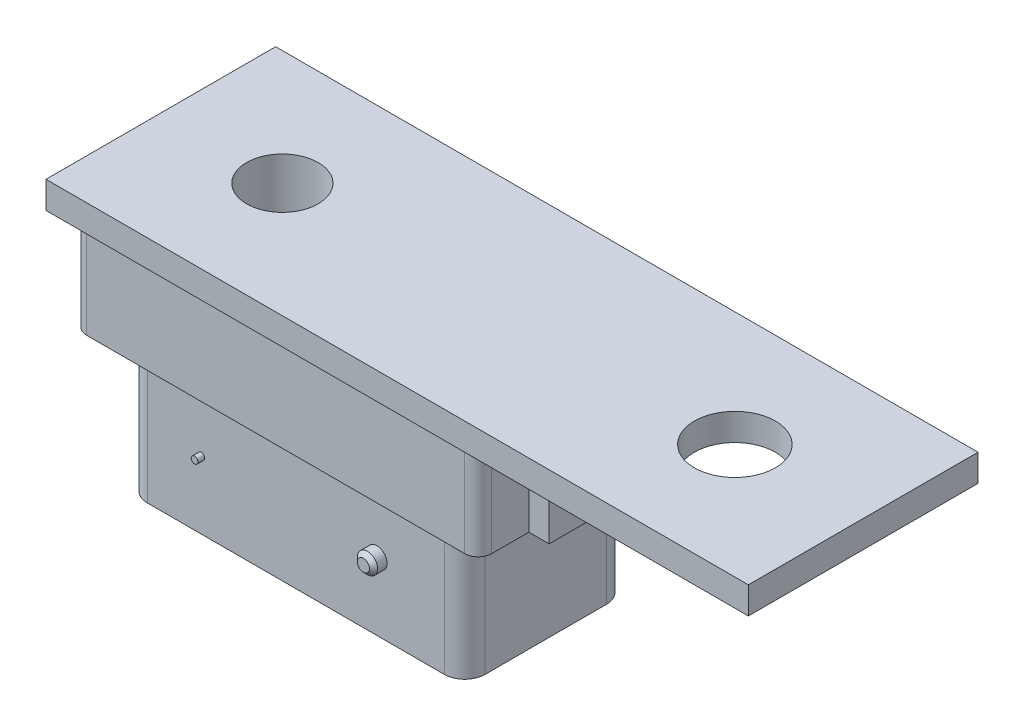
from build123d import *

# Parameters (mm, degrees)
SKETCH1_W           = 520
SKETCH1_H           = 170
BOSS_EXTRUDE1_DEPTH = 10
BOSS_EXTRUDE2_DEPTH = 75
BOSS_EXTRUDE3_DEPTH = 100
SKETCH4_W           = 7.501461654
SKETCH4_H           = 40
BOSS_EXTRUDE4_DEPTH = 25
SKETCH5_R           = 3.75
CUT_EXTRUDE1_DEPTH  = 93
SKETCH6_W           = 50
SKETCH6_H           = 75
BOSS_EXTRUDE5_DEPTH = 5
SKETCH7_R           = 30
CUT_EXTRUDE2_DEPTH  = 68
SKETCH8_W           = 75
SKETCH8_H           = 75
BOSS_EXTRUDE6_DEPTH = 15
SKETCH9_R           = 30
SKETCH9_R_2         = 26.5
BOSS_EXTRUDE7_DEPTH = 5
SKETCH11_R          = 26.5
CUT_EXTRUDE3_DEPTH  = 75
SKETCH12_R          = 26.5
CUT_EXTRUDE4_DEPTH  = 196
SKETCH14_R          = 7.5
BOSS_EXTRUDE8_DEPTH = 10
CHAMFER1_SIZE       = 3
SKETCH15_R          = 2.5
BOSS_EXTRUDE9_DEPTH = 5


with BuildPart() as part:
    # Sketch1 → Boss-Extrude1 (new body, symmetric)
    with BuildSketch(Plane(origin=(0, 0, 0), x_dir=(1, 0, 0), z_dir=(0, 1, 0))):
        Rectangle(SKETCH1_W, SKETCH1_H)
    extrude(amount=BOSS_EXTRUDE1_DEPTH, both=True)

    # Sketch2 → Boss-Extrude2 (add)
    with BuildSketch(Plane.XZ.offset(10)):
        with BuildLine():
            Line((-240, 75), (40, 75))
            ThreePointArc((40, 75), (47.071067812, 72.071067812), (50, 65))
            Line((50, 65), (50, -65))
            ThreePointArc((50, -65), (47.071067812, -72.071067812), (40, -75))
            Line((40, -75), (-240, -75))
            ThreePointArc((-240, -75), (-247.071067812, -72.071067812), (-250, -65))
            Line((-250, -65), (-250, 65))
            ThreePointArc((-250, 65), (-247.071067812, 72.071067812), (-240, 75))
        make_face()
    extrude(amount=BOSS_EXTRUDE2_DEPTH)

    # Sketch3 → Boss-Extrude3 (add)
    with BuildSketch(Plane.XZ.offset(85)):
        with BuildLine():
            Line((-210, 60), (10, 60))
            ThreePointArc((10, 60), (20.606601718, 55.606601718), (25, 45))
            Line((25, 45), (25, -45))
            ThreePointArc((25, -45), (20.606601718, -55.606601718), (10, -60))
            Line((10, -60), (-210, -60))
            ThreePointArc((-210, -60), (-220.606601718, -55.606601718), (-225, -45))
            Line((-225, -45), (-225, 45))
            ThreePointArc((-225, 45), (-220.606601718, 55.606601718), (-210, 60))
        make_face()
    extrude(amount=BOSS_EXTRUDE3_DEPTH)

    # Sketch4 → Boss-Extrude4 (add)
    with BuildSketch(Plane.ZY.offset(225)):
        with Locations((13.750730827, -135)):
            Rectangle(SKETCH4_W, SKETCH4_H)
        with Locations((-13.750730827, -135)):
            Rectangle(SKETCH4_W, SKETCH4_H)
    extrude(amount=BOSS_EXTRUDE4_DEPTH)

    # Sketch5 → Cut-Extrude1 (cut)
    with BuildSketch(Plane(origin=(0, 0, -17.501461654), x_dir=(-1, 0, 0), z_dir=(0, 0, -1))):
        with Locations((235, -135)):
            Circle(SKETCH5_R)
    extrude(amount=-CUT_EXTRUDE1_DEPTH, mode=Mode.SUBTRACT)

    # Sketch6 → Boss-Extrude5 (add)
    with BuildSketch(Plane.ZY.offset(250)):
        with Locations((0, -47.5)):
            Rectangle(SKETCH6_W, SKETCH6_H)
    extrude(amount=BOSS_EXTRUDE5_DEPTH)

    # Sketch7 → Cut-Extrude2 (cut)
    with BuildSketch(Plane.XZ.offset(10)):
        with Locations((165, 0)):
            Circle(SKETCH7_R)
    extrude(amount=-CUT_EXTRUDE2_DEPTH, mode=Mode.SUBTRACT)

    # Sketch8 → Boss-Extrude6 (add)
    with BuildSketch(Plane(origin=(50, 0, 0), x_dir=(0, 0, -1), z_dir=(1, 0, 0))):
        with Locations((0, -47.5)):
            Rectangle(SKETCH8_W, SKETCH8_H)
    extrude(amount=BOSS_EXTRUDE6_DEPTH)

    # Sketch9 → Boss-Extrude7 (add)
    with BuildSketch(Plane.XZ.offset(185)):
        with Locations((-35, 0)):
            Circle(SKETCH9_R)
        with Locations((-35, 0)):
            Circle(SKETCH9_R_2, mode=Mode.SUBTRACT)
    extrude(amount=BOSS_EXTRUDE7_DEPTH)

    # Sketch11 → Cut-Extrude3 (cut)
    with BuildSketch(Plane.XZ.offset(185)):
        with Locations((-35, 0)):
            Circle(SKETCH11_R)
    extrude(amount=-CUT_EXTRUDE3_DEPTH, mode=Mode.SUBTRACT)

    # Sketch12 → Cut-Extrude4 (cut, through all)
    with BuildSketch(Plane.XZ.offset(185)):
        with Locations((-170, 0)):
            Circle(SKETCH12_R)
    extrude(amount=-CUT_EXTRUDE4_DEPTH, mode=Mode.SUBTRACT)

    # Sketch14 → Boss-Extrude8 (add)
    with BuildSketch(Plane.XY.offset(60)):
        with Locations((-40, -135)):
            Circle(SKETCH14_R)
    extrude(amount=BOSS_EXTRUDE8_DEPTH)

    # Chamfer1
    chamfer1_edges = [part.edges().sort_by_distance(p)[0] for p in [
        (-47.5, -135, 70),
    ]]
    chamfer(chamfer1_edges, length=CHAMFER1_SIZE)

    # Sketch15 → Boss-Extrude9 (add)
    with BuildSketch(Plane.XY.offset(60)):
        with Locations((-170, -135)):
            Circle(SKETCH15_R)
    extrude(amount=BOSS_EXTRUDE9_DEPTH)


solid = part.part
